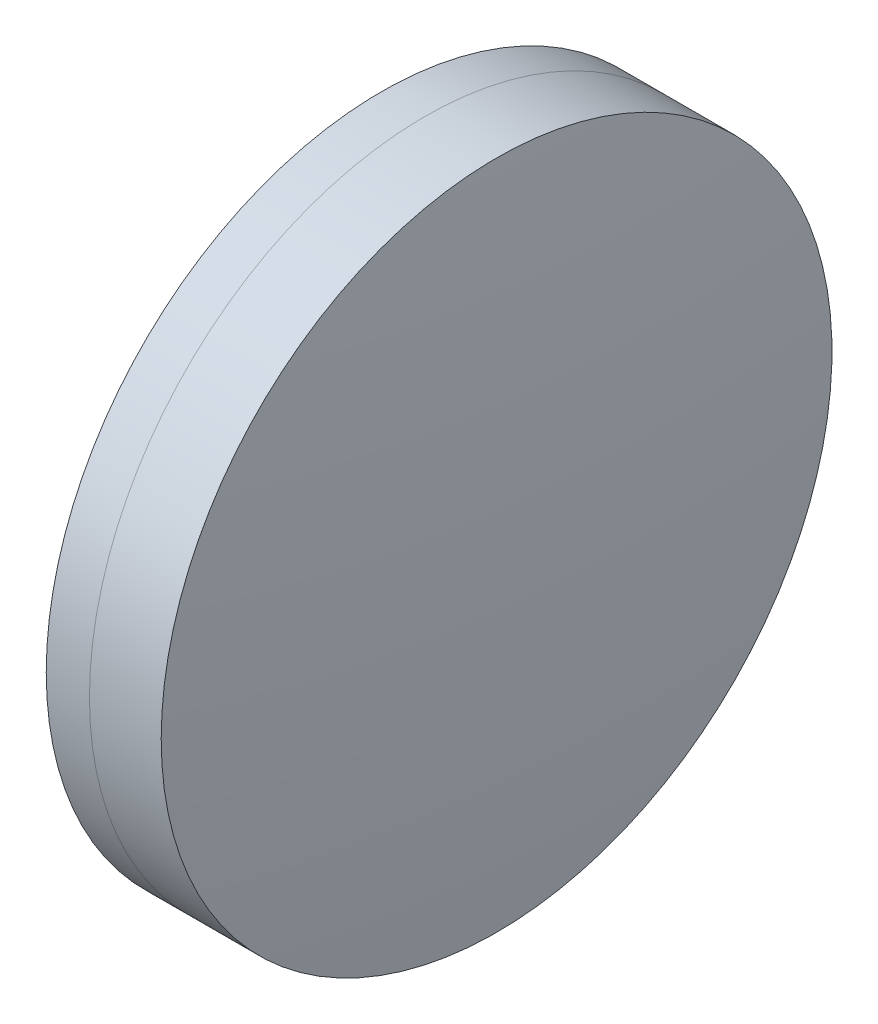
from build123d import *


with BuildPart() as part:
    # 草图1 one side → 旋转1 (revolve)
    with BuildSketch(Plane(origin=(0, 0, 0), x_dir=(1, 0, 0), z_dir=(0, 1, 0)), mode=Mode.PRIVATE) as revolve_1_sk:
        with BuildLine():
            ThreePointArc((301.957921643, 30), (299.268390633, 15.107036655), (298.367625551, 0))
            Line((298.367625551, 0), (310.707625551, 0))
            ThreePointArc((310.707625551, 0), (309.478715765, 15.197455214), (305.823919996, 30))
            Line((305.823919996, 30), (301.957921643, 30))
        make_face()
    revolve(revolve_1_sk.sketch.rotate(Axis((124.523309526, 0, 0), (1, 0, 0)), 180), axis=Axis((124.523309526, 0, 0), (1, 0, 0)))  # turned: the seam where the file's is


with BuildPart() as body_2:
    # 草图2 one side → 旋转3 (revolve)
    with BuildSketch(Plane(origin=(0, 0, 0), x_dir=(1, 0, 0), z_dir=(0, 1, 0)), mode=Mode.PRIVATE) as revolve_3_sk:
        with BuildLine():
            Line((312.241892944, 30), (305.823919996, 30))
            ThreePointArc((305.823919996, 30), (309.478715765, 15.197455214), (310.707625551, 0))
            Line((310.707625551, 0), (313.837625551, 0))
            ThreePointArc((313.837625551, 0), (313.438410623, 15.0212047), (312.241892944, 30))
        make_face()
    revolve(revolve_3_sk.sketch.rotate(Axis((-0.551919993, 0, 0), (1, 0, 0)), 180), axis=Axis((-0.551919993, 0, 0), (1, 0, 0)))  # turned: the seam where the file's is


solid = Compound([part.part, body_2.part])
